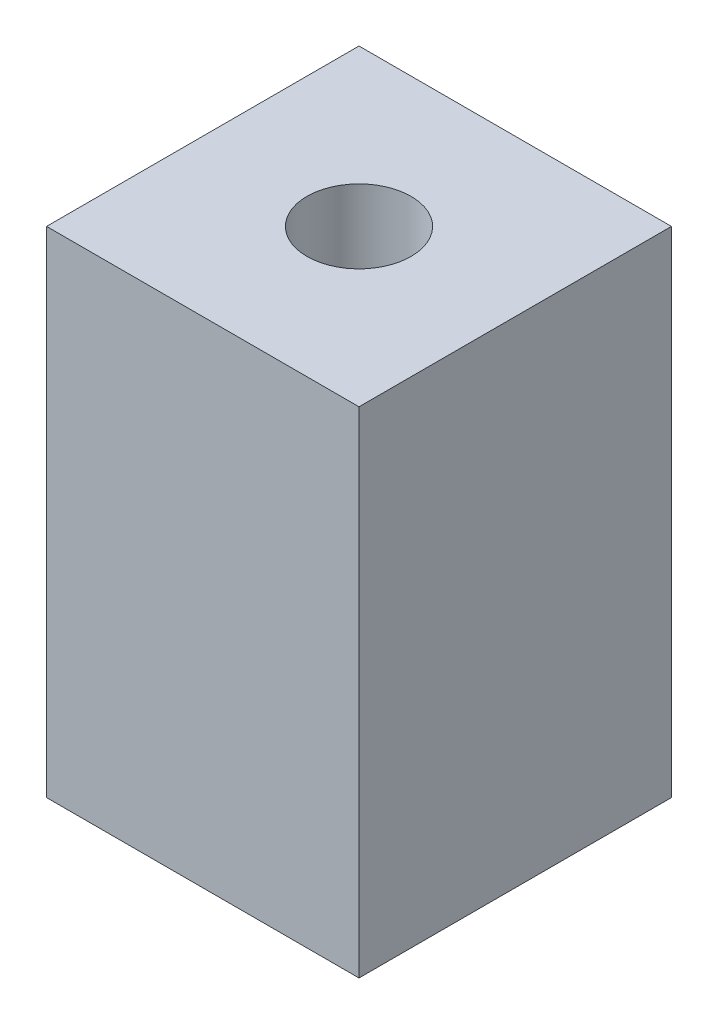
from build123d import *

# Parameters (mm, degrees)
SKETCH1_W           = 12
SKETCH1_H           = 12
SKETCH1_R           = 2
BOSS_EXTRUDE1_DEPTH = 19


with BuildPart() as part:
    # Sketch1 → Boss-Extrude1 (new body)
    with BuildSketch(Plane(origin=(0, 0, 0), x_dir=(1, 0, 0), z_dir=(0, 1, 0))):
        Rectangle(SKETCH1_W, SKETCH1_H)
        Circle(SKETCH1_R, mode=Mode.SUBTRACT)
    extrude(amount=BOSS_EXTRUDE1_DEPTH)


solid = part.part
